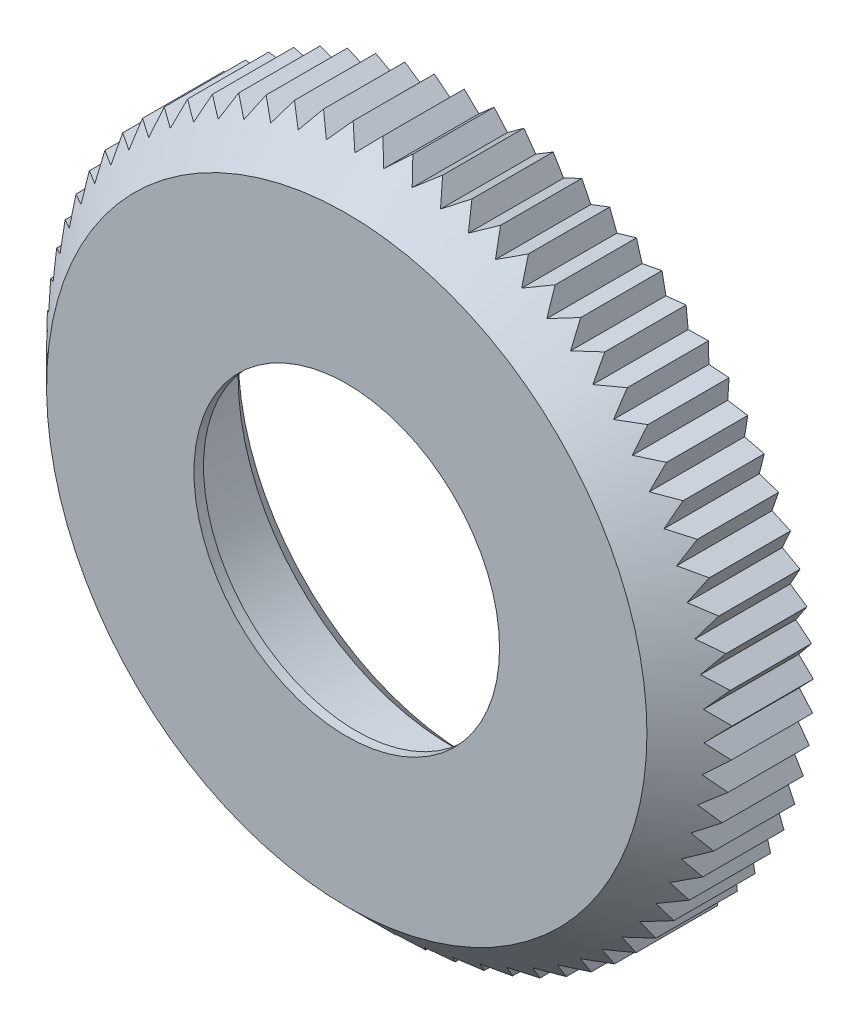
from build123d import *

# Parameters (mm, degrees)
ESQUISSE1_R                  = 17.25
ESQUISSE1_R_2                = 8.016386033
BOSS_EXTRU_1_DEPTH           = 0.5
ESQUISSE2_R                  = 17.25
ESQUISSE2_R_2                = 11.2
BOSS_EXTRU_2_DEPTH           = 6
CHANFREIN1_SIZE              = 1
CHANFREIN2_SIZE              = 1.5
BOSS_EXTRU_3_REACH           = 27.246
R_P_TITION_CIRCULAIRE1_COUNT = 72


with BuildPart() as part:
    # Esquisse1 → Boss.-Extru.1 (new body)
    with BuildSketch(Plane.XY):
        Circle(ESQUISSE1_R)
        Circle(ESQUISSE1_R_2, mode=Mode.SUBTRACT)
    extrude(amount=BOSS_EXTRU_1_DEPTH)

    # Esquisse2 → Boss.-Extru.2 (add)
    with BuildSketch(Plane(origin=(0, 0, 0), x_dir=(-1, 0, 0), z_dir=(0, 0, -1))):
        Circle(ESQUISSE2_R)
        Circle(ESQUISSE2_R_2, mode=Mode.SUBTRACT)
    extrude(amount=BOSS_EXTRU_2_DEPTH)

    # Chanfrein1
    chanfrein1_edges = [part.edges().sort_by_distance(p)[0] for p in [
        (11.2, 0, -6),
    ]]
    chamfer(chanfrein1_edges, length=CHANFREIN1_SIZE)

    # Chanfrein2
    chanfrein2_edges = [part.edges().sort_by_distance(p)[0] for p in [
        (-17.25, 0, 0.5),
    ]]
    chamfer(chanfrein2_edges, length=CHANFREIN2_SIZE)

    # Boss.-Extru.3: up to this cone (the profile starts inside it)
    boss_extru_3_end = Plane(origin=(0, 0, -6), z_dir=(0, 0, -1)).offset(-22.249999) * Cone(1e-06, 72.246, 72.245999, align=(Align.CENTER, Align.CENTER, Align.MIN), mode=Mode.PRIVATE)
    # Esquisse3 → Boss.-Extru.3 (add, up to the surface)
    with BuildSketch(Plane(origin=(0, 0, -6), x_dir=(-1, 0, 0), z_dir=(0, 0, -1)), mode=Mode.PRIVATE) as boss_extru_3_sk1:
        with BuildLine():
            Line((-1.233490455, 17.943669692), (-1.932550994, 17.141404454))
            ThreePointArc((-1.932550994, 17.141404454), (-1.183014073, 17.209386326), (-0.431225217, 17.244609152))
            Line((-0.431225217, 17.244609152), (-1.233490455, 17.943669692))
        make_face()
    boss_extru_3_tool1 = extrude(boss_extru_3_sk1.sketch, amount=-BOSS_EXTRU_3_REACH, mode=Mode.PRIVATE) & boss_extru_3_end
    boss_extru_3 = boss_extru_3_tool1.solids().sort_by_distance((1.199591, 17.45053, -6))[0]
    add(boss_extru_3)

    # Répétition circulaire1: Boss.-Extru.3 ×72 about axis
    r_p_tition_circulaire1_axis = Axis((0, 0, 0), (0, 0, 1))
    for i in range(1, R_P_TITION_CIRCULAIRE1_COUNT):
        add(boss_extru_3.rotate(r_p_tition_circulaire1_axis, i * 360 / R_P_TITION_CIRCULAIRE1_COUNT))


solid = part.part
